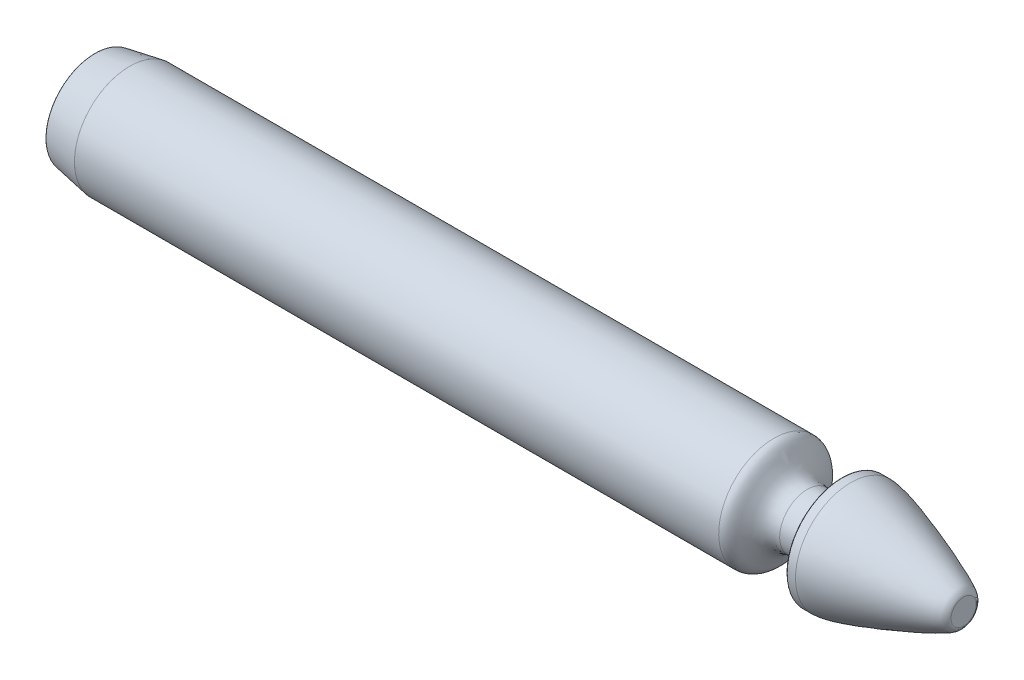
from build123d import *

# Parameters (mm, degrees)
BREAK_EDGES_R = 0.02


with BuildPart() as part:
    # body_sketch → body (revolve)
    with BuildSketch(Plane.XY):
        with BuildLine():
            Line((-16.73571407, 3.175), (-10.921788615, 3.175))
            add(Edge.make_bspline(
                [(-10.921788615, 3.175), (-10.165447426, 3.175), (-10.250040485, 1.5875), (-9, 1.5875)],
                knots=[0, 0, 0, 0, 1, 1, 1, 1], degree=3))
            Line((-9, 1.5875), (-7, 1.5875))
            Line((-7, 1.5875), (-7, 3.175))
            Line((-7, 3.175), (-6.5, 3.175))
            add(Edge.make_bspline(
                [(-6.5, 3.175), (-5.484084378, 3.175), (-0.421041724, 1.302274259), (-0.009654297, 0.817143972), (0, 0.774017781), (0, 0.724579725)],
                knots=[0, 0, 0, 0, 0.586137631, 0.686137631, 1, 1, 1, 1], degree=3))
            Line((0, 0.724579725), (0, 0))
            Line((0, 0), (-50, 0))
            Line((-50, 0), (-50, 2.822346039))
            Line((-50, 2.822346039), (-48, 3.175))
            Line((-48, 3.175), (-20.811079947, 3.175))
            add(Edge.make_bspline(
                [(-20.811079947, 3.175), (-19.383200887, 3.175), (-18.073641119, 3.175), (-16.73571407, 3.175)],
                knots=[0, 0, 0, 0, 1, 1, 1, 1], degree=3))
        make_face()
    revolve(axis=Axis((0, 0, 0), (-1, 0, 0)))

    # break_edges
    break_edges_edges = [part.edges().sort_by_distance(p)[0] for p in [
        (-7, -3.175, 0),
        (-50, -2.822346039, 0),
        (-48, -3.175, 0),
    ]]
    fillet(break_edges_edges, radius=BREAK_EDGES_R)


solid = part.part
